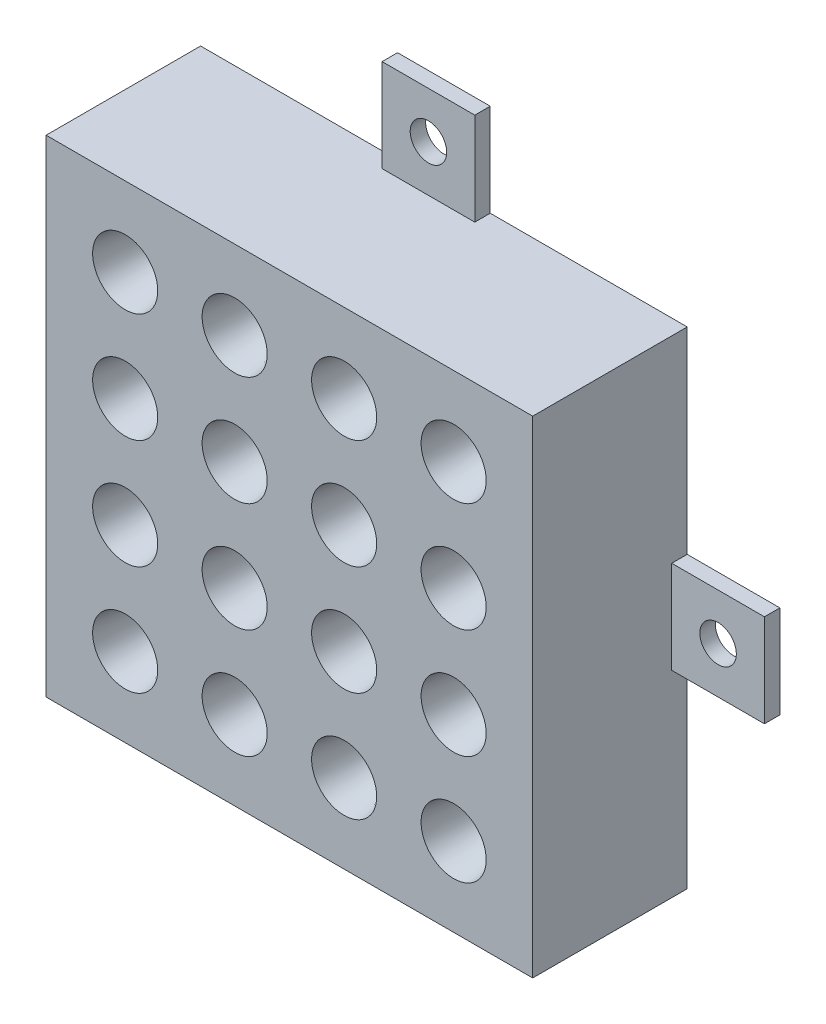
from build123d import *

# Parameters (mm, degrees)
SKETCH1_W                     = 40
SKETCH1_H                     = 40
BOSS_EXTRUDE1_DEPTH           = 12.7
SKETCH2_R                     = 2.67558437
CUT_EXTRUDE1_DEPTH            = 11.176
CUT_EXTRUDE1_DRAFT            = -8.75
CUT_EXTRUDE1_PROFILE_2_DEPTH  = 11.176
CUT_EXTRUDE1_PROFILE_2_DRAFT  = -8.75
CUT_EXTRUDE1_PROFILE_3_DEPTH  = 11.176
CUT_EXTRUDE1_PROFILE_3_DRAFT  = -8.75
CUT_EXTRUDE1_PROFILE_4_DEPTH  = 11.176
CUT_EXTRUDE1_PROFILE_4_DRAFT  = -8.75
CUT_EXTRUDE1_PROFILE_5_DEPTH  = 11.176
CUT_EXTRUDE1_PROFILE_5_DRAFT  = -8.75
CUT_EXTRUDE1_PROFILE_6_DEPTH  = 11.176
CUT_EXTRUDE1_PROFILE_6_DRAFT  = -8.75
CUT_EXTRUDE1_PROFILE_7_DEPTH  = 11.176
CUT_EXTRUDE1_PROFILE_7_DRAFT  = -8.75
CUT_EXTRUDE1_PROFILE_8_DEPTH  = 11.176
CUT_EXTRUDE1_PROFILE_8_DRAFT  = -8.75
CUT_EXTRUDE1_PROFILE_9_DEPTH  = 11.176
CUT_EXTRUDE1_PROFILE_9_DRAFT  = -8.75
CUT_EXTRUDE1_PROFILE_10_DEPTH = 11.176
CUT_EXTRUDE1_PROFILE_10_DRAFT = -8.75
CUT_EXTRUDE1_PROFILE_11_DEPTH = 11.176
CUT_EXTRUDE1_PROFILE_11_DRAFT = -8.75
CUT_EXTRUDE1_PROFILE_12_DEPTH = 11.176
CUT_EXTRUDE1_PROFILE_12_DRAFT = -8.75
CUT_EXTRUDE1_PROFILE_13_DEPTH = 11.176
CUT_EXTRUDE1_PROFILE_13_DRAFT = -8.75
CUT_EXTRUDE1_PROFILE_14_DEPTH = 11.176
CUT_EXTRUDE1_PROFILE_14_DRAFT = -8.75
CUT_EXTRUDE1_PROFILE_15_DEPTH = 11.176
CUT_EXTRUDE1_PROFILE_15_DRAFT = -8.75
CUT_EXTRUDE1_PROFILE_16_DEPTH = 11.176
CUT_EXTRUDE1_PROFILE_16_DRAFT = -8.75
SKETCH3_W                     = 7.62
SKETCH3_H                     = 1.27
BOSS_EXTRUDE2_DEPTH           = 7.62
SKETCH4_W                     = 1.27
SKETCH4_H                     = 7.62
BOSS_EXTRUDE3_DEPTH           = 7.62
SKETCH5_W                     = 1.27
SKETCH5_H                     = 7.62
BOSS_EXTRUDE4_DEPTH           = 7.62
SKETCH6_W                     = 7.62
SKETCH6_H                     = 1.27
BOSS_EXTRUDE5_DEPTH           = 7.62
SKETCH7_R                     = 1.5
M3_DIAMETER_HOLES_DEPTH       = 7.62
SKETCH8_R                     = 0.4572
SKETCH8_R_2                   = 0.02667
CUT_EXTRUDE3_DEPTH            = 2


with BuildPart() as part:
    # Sketch1 → Boss-Extrude1 (new body)
    with BuildSketch(Plane.XY):
        with Locations((-32.473746891, -5.437780853)):
            Rectangle(SKETCH1_W, SKETCH1_H)
    extrude(amount=BOSS_EXTRUDE1_DEPTH)


with BuildPart() as cut_extrude1_tool:
    # Sketch2 → Cut-Extrude1 (with draft: the straight prism first)
    with BuildSketch(Plane.XY.offset(12.7)):
        with Locations((-45.973746891, 8.062219147)):
            Circle(SKETCH2_R)
    extrude(amount=-CUT_EXTRUDE1_DEPTH)
    # Cut-Extrude1: the draft: its side faces are tilted about the plane it starts from
    cut_extrude1_sides = [cut_extrude1_tool.faces().sort_by_distance(p)[0] for p in [
        (-48.649331261, 8.062219147, 7.112),
    ]]
    draft(cut_extrude1_sides, Plane.XY.offset(12.7), CUT_EXTRUDE1_DRAFT)


with BuildPart() as part_1:
    add(part.part)

    # Cut-Extrude1: cut by cut_extrude1_tool
    add(cut_extrude1_tool.part, mode=Mode.SUBTRACT)


with BuildPart() as cut_extrude1_profile_2_tool:
    # Sketch2 → Cut-Extrude1 profile 2 (with draft: the straight prism first)
    with BuildSketch(Plane.XY.offset(12.7)):
        with Locations((-36.973746891, 8.062219147)):
            Circle(SKETCH2_R)
    extrude(amount=-CUT_EXTRUDE1_PROFILE_2_DEPTH)
    # Cut-Extrude1 profile 2: the draft: its side faces are tilted about the plane it starts from
    cut_extrude1_profile_2_sides = [cut_extrude1_profile_2_tool.faces().sort_by_distance(p)[0] for p in [
        (-39.649331261, 8.062219147, 7.112),
    ]]
    draft(cut_extrude1_profile_2_sides, Plane.XY.offset(12.7), CUT_EXTRUDE1_PROFILE_2_DRAFT)


with BuildPart() as part_2:
    add(part_1.part)

    # Cut-Extrude1 profile 2: cut by cut_extrude1_profile_2_tool
    add(cut_extrude1_profile_2_tool.part, mode=Mode.SUBTRACT)


with BuildPart() as cut_extrude1_profile_3_tool:
    # Sketch2 → Cut-Extrude1 profile 3 (with draft: the straight prism first)
    with BuildSketch(Plane.XY.offset(12.7)):
        with Locations((-27.973746891, 8.062219147)):
            Circle(SKETCH2_R)
    extrude(amount=-CUT_EXTRUDE1_PROFILE_3_DEPTH)
    # Cut-Extrude1 profile 3: the draft: its side faces are tilted about the plane it starts from
    cut_extrude1_profile_3_sides = [cut_extrude1_profile_3_tool.faces().sort_by_distance(p)[0] for p in [
        (-30.649331261, 8.062219147, 7.112),
    ]]
    draft(cut_extrude1_profile_3_sides, Plane.XY.offset(12.7), CUT_EXTRUDE1_PROFILE_3_DRAFT)


with BuildPart() as part_3:
    add(part_2.part)

    # Cut-Extrude1 profile 3: cut by cut_extrude1_profile_3_tool
    add(cut_extrude1_profile_3_tool.part, mode=Mode.SUBTRACT)


with BuildPart() as cut_extrude1_profile_4_tool:
    # Sketch2 → Cut-Extrude1 profile 4 (with draft: the straight prism first)
    with BuildSketch(Plane.XY.offset(12.7)):
        with Locations((-18.973746891, 8.062219147)):
            Circle(SKETCH2_R)
    extrude(amount=-CUT_EXTRUDE1_PROFILE_4_DEPTH)
    # Cut-Extrude1 profile 4: the draft: its side faces are tilted about the plane it starts from
    cut_extrude1_profile_4_sides = [cut_extrude1_profile_4_tool.faces().sort_by_distance(p)[0] for p in [
        (-21.649331261, 8.062219147, 7.112),
    ]]
    draft(cut_extrude1_profile_4_sides, Plane.XY.offset(12.7), CUT_EXTRUDE1_PROFILE_4_DRAFT)


with BuildPart() as part_4:
    add(part_3.part)

    # Cut-Extrude1 profile 4: cut by cut_extrude1_profile_4_tool
    add(cut_extrude1_profile_4_tool.part, mode=Mode.SUBTRACT)


with BuildPart() as cut_extrude1_profile_5_tool:
    # Sketch2 → Cut-Extrude1 profile 5 (with draft: the straight prism first)
    with BuildSketch(Plane.XY.offset(12.7)):
        with Locations((-45.973746891, -0.937780853)):
            Circle(SKETCH2_R)
    extrude(amount=-CUT_EXTRUDE1_PROFILE_5_DEPTH)
    # Cut-Extrude1 profile 5: the draft: its side faces are tilted about the plane it starts from
    cut_extrude1_profile_5_sides = [cut_extrude1_profile_5_tool.faces().sort_by_distance(p)[0] for p in [
        (-48.649331261, -0.937780853, 7.112),
    ]]
    draft(cut_extrude1_profile_5_sides, Plane.XY.offset(12.7), CUT_EXTRUDE1_PROFILE_5_DRAFT)


with BuildPart() as part_5:
    add(part_4.part)

    # Cut-Extrude1 profile 5: cut by cut_extrude1_profile_5_tool
    add(cut_extrude1_profile_5_tool.part, mode=Mode.SUBTRACT)


with BuildPart() as cut_extrude1_profile_6_tool:
    # Sketch2 → Cut-Extrude1 profile 6 (with draft: the straight prism first)
    with BuildSketch(Plane.XY.offset(12.7)):
        with Locations((-36.973746891, -0.937780853)):
            Circle(SKETCH2_R)
    extrude(amount=-CUT_EXTRUDE1_PROFILE_6_DEPTH)
    # Cut-Extrude1 profile 6: the draft: its side faces are tilted about the plane it starts from
    cut_extrude1_profile_6_sides = [cut_extrude1_profile_6_tool.faces().sort_by_distance(p)[0] for p in [
        (-39.649331261, -0.937780853, 7.112),
    ]]
    draft(cut_extrude1_profile_6_sides, Plane.XY.offset(12.7), CUT_EXTRUDE1_PROFILE_6_DRAFT)


with BuildPart() as part_6:
    add(part_5.part)

    # Cut-Extrude1 profile 6: cut by cut_extrude1_profile_6_tool
    add(cut_extrude1_profile_6_tool.part, mode=Mode.SUBTRACT)


with BuildPart() as cut_extrude1_profile_7_tool:
    # Sketch2 → Cut-Extrude1 profile 7 (with draft: the straight prism first)
    with BuildSketch(Plane.XY.offset(12.7)):
        with Locations((-27.973746891, -0.937780853)):
            Circle(SKETCH2_R)
    extrude(amount=-CUT_EXTRUDE1_PROFILE_7_DEPTH)
    # Cut-Extrude1 profile 7: the draft: its side faces are tilted about the plane it starts from
    cut_extrude1_profile_7_sides = [cut_extrude1_profile_7_tool.faces().sort_by_distance(p)[0] for p in [
        (-30.649331261, -0.937780853, 7.112),
    ]]
    draft(cut_extrude1_profile_7_sides, Plane.XY.offset(12.7), CUT_EXTRUDE1_PROFILE_7_DRAFT)


with BuildPart() as part_7:
    add(part_6.part)

    # Cut-Extrude1 profile 7: cut by cut_extrude1_profile_7_tool
    add(cut_extrude1_profile_7_tool.part, mode=Mode.SUBTRACT)


with BuildPart() as cut_extrude1_profile_8_tool:
    # Sketch2 → Cut-Extrude1 profile 8 (with draft: the straight prism first)
    with BuildSketch(Plane.XY.offset(12.7)):
        with Locations((-18.973746891, -0.937780853)):
            Circle(SKETCH2_R)
    extrude(amount=-CUT_EXTRUDE1_PROFILE_8_DEPTH)
    # Cut-Extrude1 profile 8: the draft: its side faces are tilted about the plane it starts from
    cut_extrude1_profile_8_sides = [cut_extrude1_profile_8_tool.faces().sort_by_distance(p)[0] for p in [
        (-21.649331261, -0.937780853, 7.112),
    ]]
    draft(cut_extrude1_profile_8_sides, Plane.XY.offset(12.7), CUT_EXTRUDE1_PROFILE_8_DRAFT)


with BuildPart() as part_8:
    add(part_7.part)

    # Cut-Extrude1 profile 8: cut by cut_extrude1_profile_8_tool
    add(cut_extrude1_profile_8_tool.part, mode=Mode.SUBTRACT)


with BuildPart() as cut_extrude1_profile_9_tool:
    # Sketch2 → Cut-Extrude1 profile 9 (with draft: the straight prism first)
    with BuildSketch(Plane.XY.offset(12.7)):
        with Locations((-45.973746891, -9.937780853)):
            Circle(SKETCH2_R)
    extrude(amount=-CUT_EXTRUDE1_PROFILE_9_DEPTH)
    # Cut-Extrude1 profile 9: the draft: its side faces are tilted about the plane it starts from
    cut_extrude1_profile_9_sides = [cut_extrude1_profile_9_tool.faces().sort_by_distance(p)[0] for p in [
        (-48.649331261, -9.937780853, 7.112),
    ]]
    draft(cut_extrude1_profile_9_sides, Plane.XY.offset(12.7), CUT_EXTRUDE1_PROFILE_9_DRAFT)


with BuildPart() as part_9:
    add(part_8.part)

    # Cut-Extrude1 profile 9: cut by cut_extrude1_profile_9_tool
    add(cut_extrude1_profile_9_tool.part, mode=Mode.SUBTRACT)


with BuildPart() as cut_extrude1_profile_10_tool:
    # Sketch2 → Cut-Extrude1 profile 10 (with draft: the straight prism first)
    with BuildSketch(Plane.XY.offset(12.7)):
        with Locations((-36.973746891, -9.937780853)):
            Circle(SKETCH2_R)
    extrude(amount=-CUT_EXTRUDE1_PROFILE_10_DEPTH)
    # Cut-Extrude1 profile 10: the draft: its side faces are tilted about the plane it starts from
    cut_extrude1_profile_10_sides = [cut_extrude1_profile_10_tool.faces().sort_by_distance(p)[0] for p in [
        (-39.649331261, -9.937780853, 7.112),
    ]]
    draft(cut_extrude1_profile_10_sides, Plane.XY.offset(12.7), CUT_EXTRUDE1_PROFILE_10_DRAFT)


with BuildPart() as part_10:
    add(part_9.part)

    # Cut-Extrude1 profile 10: cut by cut_extrude1_profile_10_tool
    add(cut_extrude1_profile_10_tool.part, mode=Mode.SUBTRACT)


with BuildPart() as cut_extrude1_profile_11_tool:
    # Sketch2 → Cut-Extrude1 profile 11 (with draft: the straight prism first)
    with BuildSketch(Plane.XY.offset(12.7)):
        with Locations((-27.973746891, -9.937780853)):
            Circle(SKETCH2_R)
    extrude(amount=-CUT_EXTRUDE1_PROFILE_11_DEPTH)
    # Cut-Extrude1 profile 11: the draft: its side faces are tilted about the plane it starts from
    cut_extrude1_profile_11_sides = [cut_extrude1_profile_11_tool.faces().sort_by_distance(p)[0] for p in [
        (-30.649331261, -9.937780853, 7.112),
    ]]
    draft(cut_extrude1_profile_11_sides, Plane.XY.offset(12.7), CUT_EXTRUDE1_PROFILE_11_DRAFT)


with BuildPart() as part_11:
    add(part_10.part)

    # Cut-Extrude1 profile 11: cut by cut_extrude1_profile_11_tool
    add(cut_extrude1_profile_11_tool.part, mode=Mode.SUBTRACT)


with BuildPart() as cut_extrude1_profile_12_tool:
    # Sketch2 → Cut-Extrude1 profile 12 (with draft: the straight prism first)
    with BuildSketch(Plane.XY.offset(12.7)):
        with Locations((-18.973746891, -9.937780853)):
            Circle(SKETCH2_R)
    extrude(amount=-CUT_EXTRUDE1_PROFILE_12_DEPTH)
    # Cut-Extrude1 profile 12: the draft: its side faces are tilted about the plane it starts from
    cut_extrude1_profile_12_sides = [cut_extrude1_profile_12_tool.faces().sort_by_distance(p)[0] for p in [
        (-21.649331261, -9.937780853, 7.112),
    ]]
    draft(cut_extrude1_profile_12_sides, Plane.XY.offset(12.7), CUT_EXTRUDE1_PROFILE_12_DRAFT)


with BuildPart() as part_12:
    add(part_11.part)

    # Cut-Extrude1 profile 12: cut by cut_extrude1_profile_12_tool
    add(cut_extrude1_profile_12_tool.part, mode=Mode.SUBTRACT)


with BuildPart() as cut_extrude1_profile_13_tool:
    # Sketch2 → Cut-Extrude1 profile 13 (with draft: the straight prism first)
    with BuildSketch(Plane.XY.offset(12.7)):
        with Locations((-45.973746891, -18.937780853)):
            Circle(SKETCH2_R)
    extrude(amount=-CUT_EXTRUDE1_PROFILE_13_DEPTH)
    # Cut-Extrude1 profile 13: the draft: its side faces are tilted about the plane it starts from
    cut_extrude1_profile_13_sides = [cut_extrude1_profile_13_tool.faces().sort_by_distance(p)[0] for p in [
        (-48.649331261, -18.937780853, 7.112),
    ]]
    draft(cut_extrude1_profile_13_sides, Plane.XY.offset(12.7), CUT_EXTRUDE1_PROFILE_13_DRAFT)


with BuildPart() as part_13:
    add(part_12.part)

    # Cut-Extrude1 profile 13: cut by cut_extrude1_profile_13_tool
    add(cut_extrude1_profile_13_tool.part, mode=Mode.SUBTRACT)


with BuildPart() as cut_extrude1_profile_14_tool:
    # Sketch2 → Cut-Extrude1 profile 14 (with draft: the straight prism first)
    with BuildSketch(Plane.XY.offset(12.7)):
        with Locations((-36.973746891, -18.937780853)):
            Circle(SKETCH2_R)
    extrude(amount=-CUT_EXTRUDE1_PROFILE_14_DEPTH)
    # Cut-Extrude1 profile 14: the draft: its side faces are tilted about the plane it starts from
    cut_extrude1_profile_14_sides = [cut_extrude1_profile_14_tool.faces().sort_by_distance(p)[0] for p in [
        (-39.649331261, -18.937780853, 7.112),
    ]]
    draft(cut_extrude1_profile_14_sides, Plane.XY.offset(12.7), CUT_EXTRUDE1_PROFILE_14_DRAFT)


with BuildPart() as part_14:
    add(part_13.part)

    # Cut-Extrude1 profile 14: cut by cut_extrude1_profile_14_tool
    add(cut_extrude1_profile_14_tool.part, mode=Mode.SUBTRACT)


with BuildPart() as cut_extrude1_profile_15_tool:
    # Sketch2 → Cut-Extrude1 profile 15 (with draft: the straight prism first)
    with BuildSketch(Plane.XY.offset(12.7)):
        with Locations((-27.973746891, -18.937780853)):
            Circle(SKETCH2_R)
    extrude(amount=-CUT_EXTRUDE1_PROFILE_15_DEPTH)
    # Cut-Extrude1 profile 15: the draft: its side faces are tilted about the plane it starts from
    cut_extrude1_profile_15_sides = [cut_extrude1_profile_15_tool.faces().sort_by_distance(p)[0] for p in [
        (-30.649331261, -18.937780853, 7.112),
    ]]
    draft(cut_extrude1_profile_15_sides, Plane.XY.offset(12.7), CUT_EXTRUDE1_PROFILE_15_DRAFT)


with BuildPart() as part_15:
    add(part_14.part)

    # Cut-Extrude1 profile 15: cut by cut_extrude1_profile_15_tool
    add(cut_extrude1_profile_15_tool.part, mode=Mode.SUBTRACT)


with BuildPart() as cut_extrude1_profile_16_tool:
    # Sketch2 → Cut-Extrude1 profile 16 (with draft: the straight prism first)
    with BuildSketch(Plane.XY.offset(12.7)):
        with Locations((-18.973746891, -18.937780853)):
            Circle(SKETCH2_R)
    extrude(amount=-CUT_EXTRUDE1_PROFILE_16_DEPTH)
    # Cut-Extrude1 profile 16: the draft: its side faces are tilted about the plane it starts from
    cut_extrude1_profile_16_sides = [cut_extrude1_profile_16_tool.faces().sort_by_distance(p)[0] for p in [
        (-21.649331261, -18.937780853, 7.112),
    ]]
    draft(cut_extrude1_profile_16_sides, Plane.XY.offset(12.7), CUT_EXTRUDE1_PROFILE_16_DRAFT)


with BuildPart() as part_16:
    add(part_15.part)

    # Cut-Extrude1 profile 16: cut by cut_extrude1_profile_16_tool
    add(cut_extrude1_profile_16_tool.part, mode=Mode.SUBTRACT)

    # Sketch3 → Boss-Extrude2 (add)
    with BuildSketch(Plane(origin=(0, 14.562219147, 0), x_dir=(1, 0, 0), z_dir=(0, 1, 0))):
        with Locations((-32.473706891, -0.635)):
            Rectangle(SKETCH3_W, SKETCH3_H)
    extrude(amount=BOSS_EXTRUDE2_DEPTH)

    # Sketch4 → Boss-Extrude3 (add)
    with BuildSketch(Plane(origin=(-12.473746891, 0, 0), x_dir=(0, 0, -1), z_dir=(1, 0, 0))):
        with Locations((-0.635, -5.437820853)):
            Rectangle(SKETCH4_W, SKETCH4_H)
    extrude(amount=BOSS_EXTRUDE3_DEPTH)

    # Sketch5 → Boss-Extrude4 (add)
    with BuildSketch(Plane.ZY.offset(52.473746891)):
        with Locations((0.635, -5.437740853)):
            Rectangle(SKETCH5_W, SKETCH5_H)
    extrude(amount=BOSS_EXTRUDE4_DEPTH)

    # Sketch6 → Boss-Extrude5 (add)
    with BuildSketch(Plane.XZ.offset(25.437780853)):
        with Locations((-32.473786891, 0.635)):
            Rectangle(SKETCH6_W, SKETCH6_H)
    extrude(amount=BOSS_EXTRUDE5_DEPTH)

    # Sketch7 → M3 diameter holes (cut)
    with BuildSketch(Plane.XY.offset(1.27)):
        with Locations((-32.473786891, -29.247780853)):
            Circle(SKETCH7_R)
        with Locations((-56.283746891, -5.437740853)):
            Circle(SKETCH7_R)
        with Locations((-8.663746891, -5.437820853)):
            Circle(SKETCH7_R)
        with Locations((-32.473706891, 18.372219147)):
            Circle(SKETCH7_R)
    extrude(amount=-M3_DIAMETER_HOLES_DEPTH, mode=Mode.SUBTRACT)

    # Sketch15 → Ø1.0 (1) Diameter Hole1 (revolve, cut)
    with BuildSketch(Plane(origin=(-41.473746891, -25.437780853, 5), x_dir=(0, 0.2588190451025215, -0.9659258262890681), z_dir=(1, 0, 0))):
        Polygon((0, 0), (0, 5.30043031), (0.5, 5), (0.5, 0), align=None)
    revolve(axis=Axis((-41.473746891, -31.57140985, 3.356499064), (0, 0.9659258262890681, 0.2588190451025215)), mode=Mode.SUBTRACT)

    # Sketch8 → Cut-Extrude3 (cut, along a direction that is not the sketch's normal)
    with BuildSketch(Plane.XZ.offset(25.437780853)):
        with Locations((-41.473746891, 5)):
            Circle(SKETCH8_R)
        with Locations((-41.473746891, 5)):
            Circle(SKETCH8_R_2, mode=Mode.SUBTRACT)
    extrude(amount=-CUT_EXTRUDE3_DEPTH, dir=(0, -0.9659258262890681, -0.2588190451025215), mode=Mode.SUBTRACT)


with BuildPart() as cut_extrude3_piece_1:
    # of the separate pieces the step leaves, piece 1, a body of its own (cut_extrude3_pieces)
    add(part_16.part.solids().sort_by_distance((-52.473746891, 14.562219147, 0))[0])


with BuildPart() as cut_extrude3_piece_2:
    # of the separate pieces the step leaves, piece 2, a body of its own (cut_extrude3_pieces)
    add(part_16.part.solids().sort_by_distance((-41.500416891, -25.437780853, 5))[0])


solid = Compound([cut_extrude3_piece_1.part, cut_extrude3_piece_2.part])
